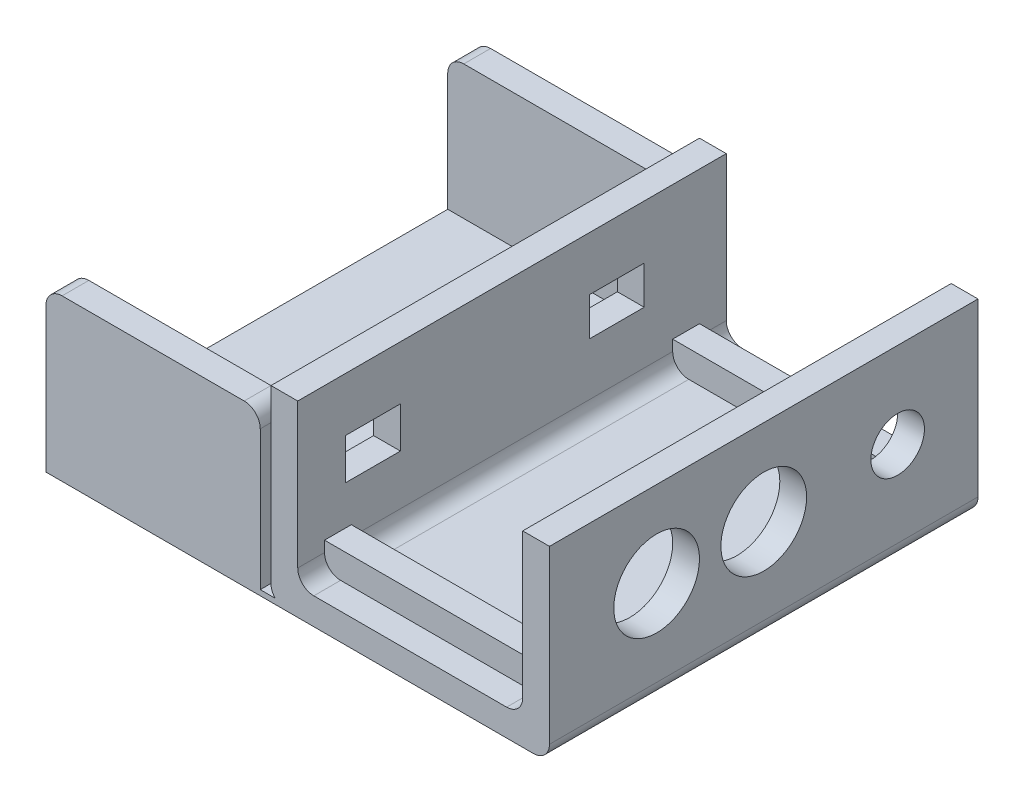
from build123d import *

# Parameters (mm, degrees)
SKETCH4_W            = 52
SKETCH4_H            = 80
BOSS_EXTRUDE4_DEPTH  = 5
SKETCH6_W            = 5
SKETCH6_H            = 80
BOSS_EXTRUDE5_DEPTH  = 35
SKETCH7_W            = 5
SKETCH7_H            = 80
BOSS_EXTRUDE6_DEPTH  = 35
SKETCH8_W            = 42
SKETCH8_H            = 5
BOSS_EXTRUDE7_DEPTH  = 5
FILLET2_R            = 3
FILLET3_R            = 3
FILLET4_R            = 3
SKETCH9_R            = 8
SKETCH9_R_2          = 5
CUT_EXTRUDE1_DEPTH   = 5
SKETCH10_W           = 5
SKETCH10_H           = 2
BOSS_EXTRUDE8_DEPTH  = 1
SKETCH11_W           = 40
SKETCH11_H           = 80
BOSS_EXTRUDE9_DEPTH  = 5
SKETCH12_W           = 40
SKETCH12_H           = 5
BOSS_EXTRUDE11_DEPTH = 30
FILLET6_R            = 3
SKETCH13_W           = 10.232646845
SKETCH13_H           = 7.639513139
SKETCH13_W_2         = 10.199522787
SKETCH13_H_2         = 7.142143056
CUT_EXTRUDE2_DEPTH   = 30


with BuildPart() as part:
    # Sketch4 → Boss-Extrude4 (new body)
    with BuildSketch(Plane(origin=(0, 0, 0), x_dir=(1, 0, 0), z_dir=(0, 1, 0))):
        with Locations((26, 40)):
            Rectangle(SKETCH4_W, SKETCH4_H)
    extrude(amount=BOSS_EXTRUDE4_DEPTH)

    # Sketch6 → Boss-Extrude5 (add)
    with BuildSketch(Plane.XZ):
        with Locations((49.5, -40)):
            Rectangle(SKETCH6_W, SKETCH6_H)
    extrude(amount=-BOSS_EXTRUDE5_DEPTH)

    # Sketch7 → Boss-Extrude6 (add)
    with BuildSketch(Plane(origin=(0, 0, 0), x_dir=(-1, 0, 0), z_dir=(0, -1, 0))):
        with Locations((-2.5, 40)):
            Rectangle(SKETCH7_W, SKETCH7_H)
    extrude(amount=-BOSS_EXTRUDE6_DEPTH)

    # Sketch8 → Boss-Extrude7 (add)
    with BuildSketch(Plane(origin=(0, 5, 0), x_dir=(1, 0, 0), z_dir=(0, 1, 0))):
        with Locations((26, 72.5)):
            Rectangle(SKETCH8_W, SKETCH8_H)
        with Locations((26, 7.5)):
            Rectangle(SKETCH8_W, SKETCH8_H)
    extrude(amount=BOSS_EXTRUDE7_DEPTH)

    # Fillet2
    fillet2_edges = [part.edges().sort_by_distance(p)[0] for p in [
        (52, 0, -40),
    ]]
    fillet(fillet2_edges, radius=FILLET2_R)

    # Fillet3
    fillet3_edges = [part.edges().sort_by_distance(p)[0] for p in [
        (47, 5, -2.5),
    ]]
    fillet(fillet3_edges, radius=FILLET3_R)

    # Fillet4
    fillet4_edges = [part.edges().sort_by_distance(p)[0] for p in [
        (5, 5, -77.5),
        (5, 5, -40),
        (47, 5, -77.5),
        (0, 0, -40),
        (5, 5, -2.5),
        (47, 5, -40),
    ]]
    fillet(fillet4_edges, radius=FILLET4_R)

    # Sketch9 → Cut-Extrude1 (cut)
    with BuildSketch(Plane(origin=(52, 0, 0), x_dir=(0, 0, -1), z_dir=(1, 0, 0))):
        with Locations((20, 19)):
            Circle(SKETCH9_R)
        with Locations((40, 19)):
            Circle(SKETCH9_R)
        with Locations((65, 19)):
            Circle(SKETCH9_R_2)
    extrude(amount=-CUT_EXTRUDE1_DEPTH, mode=Mode.SUBTRACT)

    # Sketch10 → Boss-Extrude8 (add)
    with BuildSketch(Plane(origin=(0, 0, 0), x_dir=(1, 0, 0), z_dir=(0, 1, 0))):
        with Locations((0.5, 1)):
            Rectangle(SKETCH10_W, SKETCH10_H)
        with Locations((0.5, 79)):
            Rectangle(SKETCH10_W, SKETCH10_H)
    extrude(amount=BOSS_EXTRUDE8_DEPTH)

    # Sketch11 → Boss-Extrude9 (add)
    with BuildSketch(Plane.XZ):
        with Locations((-22, -40)):
            Rectangle(SKETCH11_W, SKETCH11_H)
    extrude(amount=-BOSS_EXTRUDE9_DEPTH)

    # Sketch12 → Boss-Extrude11 (add)
    with BuildSketch(Plane.XZ):
        with Locations((-22, -2.5)):
            Rectangle(SKETCH12_W, SKETCH12_H)
        with Locations((-22, -77.5)):
            Rectangle(SKETCH12_W, SKETCH12_H)
    extrude(amount=-BOSS_EXTRUDE11_DEPTH)

    # Fillet6
    fillet6_edges = [part.edges().sort_by_distance(p)[0] for p in [
        (-42, 30, -2.5),
        (-2, 30, -2.5),
        (-42, 30, -77.5),
        (-2, 30, -77.5),
    ]]
    fillet(fillet6_edges, radius=FILLET6_R)

    # Sketch13 → Cut-Extrude2 (cut)
    with BuildSketch(Plane(origin=(5, 0, 0), x_dir=(0, 0, -1), z_dir=(1, 0, 0))):
        with Locations((14.052030706, 21.139780505)):
            Rectangle(SKETCH13_W, SKETCH13_H)
        with Locations((59.580586702, 21.388465546)):
            Rectangle(SKETCH13_W_2, SKETCH13_H_2)
    extrude(amount=-CUT_EXTRUDE2_DEPTH, mode=Mode.SUBTRACT)


solid = part.part
